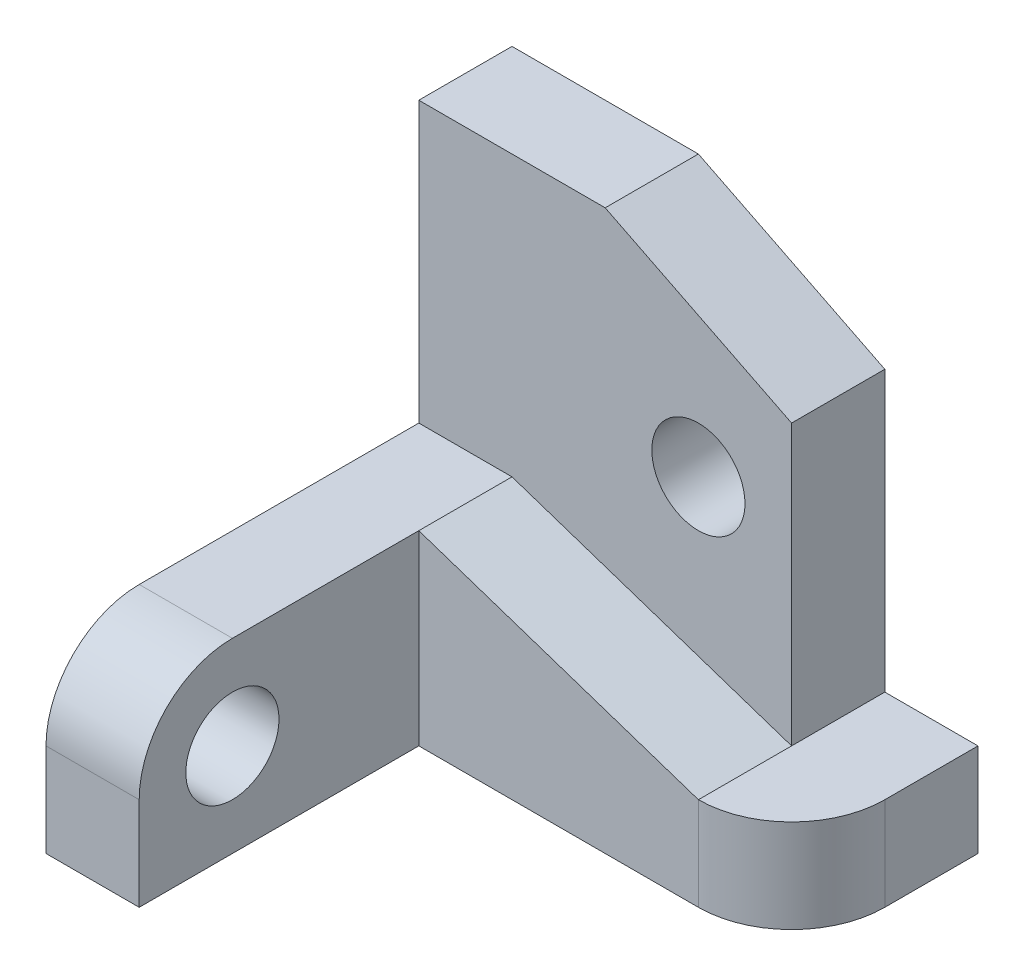
from build123d import *

# Parameters (mm, degrees)
EXTRUDE_1_DEPTH     = 5
SKETCH_1_3_W        = 20
SKETCH_1_3_H        = 5
EXTRUDE_2_DEPTH     = 10
SKETCH_1_4_W        = 20
SKETCH_1_4_H        = 5
EXTRUDE_3_DEPTH     = 25
SKETCH_2_R          = 2.5
CUT_EXTRUDE_1_DEPTH = 25
CUT_EXTRUDE_2_DEPTH = 5
SKETCH_4_R          = 2.5
EXTRUDE_4_DEPTH     = 5
SCALE_1_SCALE       = 0.2


with BuildPart() as part:
    # 草圖1 → 填料-伸長1 (new body)
    with BuildSketch(Plane(origin=(0, 0, 0), x_dir=(1, 0, 0), z_dir=(0, 1, 0))):
        with BuildLine():
            Line((20, 10), (20, 5))
            Line((20, 5), (20, 0))
            ThreePointArc((20, 0), (23.535533906, 1.464466094), (25, 5))
            Line((25, 5), (25, 10))
            Line((25, 10), (20, 10))
        make_face()
    extrude(amount=EXTRUDE_1_DEPTH)

    # 草圖1<3> → 填料-伸長2 (add)
    with BuildSketch(Plane(origin=(0, 0, 0), x_dir=(1, 0, 0), z_dir=(0, 1, 0))):
        with Locations((10, 2.5)):
            Rectangle(SKETCH_1_3_W, SKETCH_1_3_H)
    extrude(amount=EXTRUDE_2_DEPTH)

    # 草圖1<4> → 填料-伸長3 (add)
    with BuildSketch(Plane(origin=(0, 0, 0), x_dir=(1, 0, 0), z_dir=(0, 1, 0))):
        with Locations((10, 7.5)):
            Rectangle(SKETCH_1_4_W, SKETCH_1_4_H)
    extrude(amount=EXTRUDE_3_DEPTH)

    # 草圖2 → 除料-伸長1 (cut)
    with BuildSketch(Plane.XY.offset(-5)):
        with Locations((15, 15)):
            Circle(SKETCH_2_R)
        Polygon((10, 25), (20, 20), (20, 25), align=None)
    extrude(amount=-CUT_EXTRUDE_1_DEPTH, mode=Mode.SUBTRACT)

    # 草圖3 → 除料-伸長2 (cut)
    with BuildSketch(Plane.XY):
        Polygon((20, 5), (5, 10), (20, 10), align=None)
    extrude(amount=-CUT_EXTRUDE_2_DEPTH, mode=Mode.SUBTRACT)

    # 草圖4 → 填料-伸長4 (add)
    with BuildSketch(Plane(origin=(0, 0, 0), x_dir=(0, 0, -1), z_dir=(1, 0, 0))):
        with BuildLine():
            Line((0, 10), (-10, 10))
            ThreePointArc((-10, 10), (-13.535533906, 8.535533906), (-15, 5))
            Line((-15, 5), (-15, 0))
            Line((-15, 0), (0, 0))
            Line((0, 0), (0, 10))
        make_face()
        with Locations((-10, 5)):
            Circle(SKETCH_4_R, mode=Mode.SUBTRACT)
    extrude(amount=EXTRUDE_4_DEPTH)


with BuildPart() as part_1:
    # 縮放比例1: scaled about (8.934190185, 8.603677977, -4.077878453)
    add(part.part.scale(SCALE_1_SCALE).moved(Location((7.147352148, 6.882942382, -3.262302762))))


solid = part_1.part
